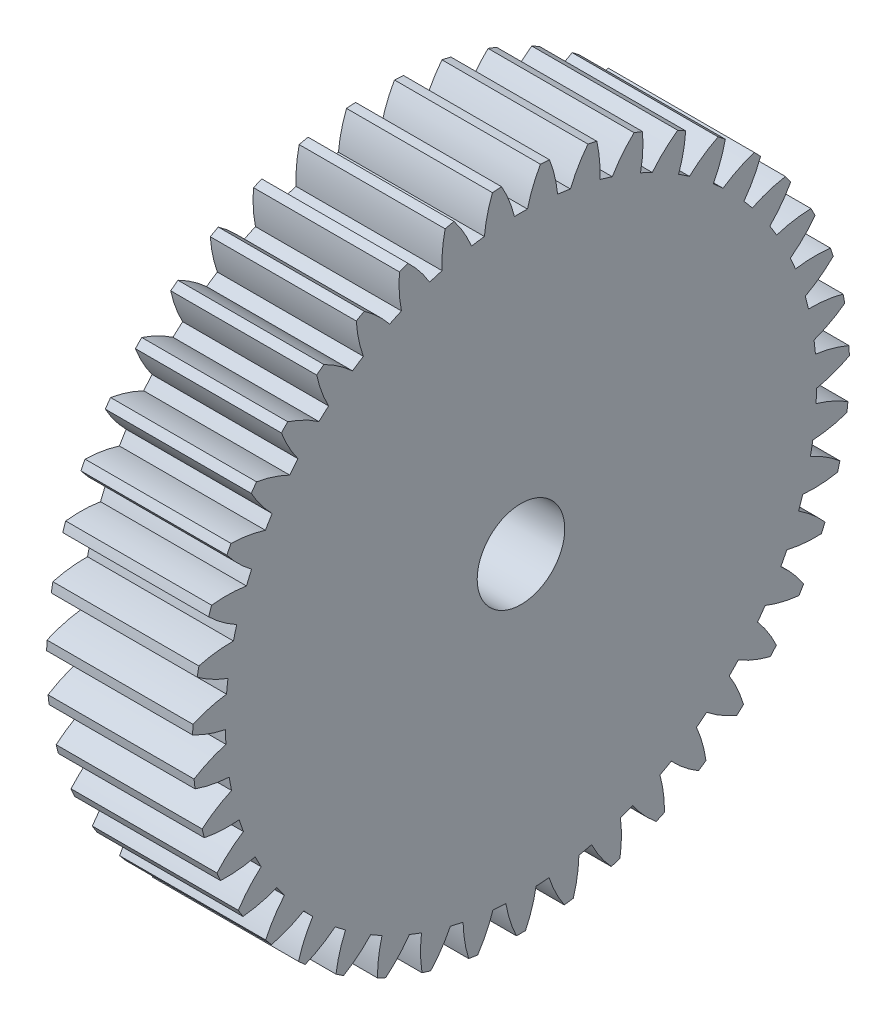
from build123d import *

# Parameters (mm, degrees)
BASPROSKE_W     = 10
BASPROSKE_H     = 22.5
TOOTHCUT_DEPTH  = 34.35416016
TEETHCUTS_COUNT = 43
TEETHCUTS_ANGLE = 351.627906977
BORSKE_R        = 3
BORE_DEPTH      = 50.0000508


with BuildPart() as part:
    # BasProSke → Base-Revolve (revolve)
    with BuildSketch(Plane(origin=(0, 0, 0), x_dir=(1, 0, 0), z_dir=(0, 1, 0)), mode=Mode.PRIVATE) as base_revolve_sk:
        with Locations((5, 11.25)):
            Rectangle(BASPROSKE_W, BASPROSKE_H)
    revolve(base_revolve_sk.sketch.rotate(Axis((-10, 0, 0), (1, 0, 0)), 180), axis=Axis((-10, 0, 0), (1, 0, 0)))

    # TooCutSke → ToothCut (cut, through all)
    with BuildSketch(Plane(origin=(0, 0, 0), x_dir=(0, 0, -1), z_dir=(1, 0, 0))):
        with BuildLine():
            ThreePointArc((0.444866364, 20.244112599), (0, 20.249), (-0.444866364, 20.244112599))
            ThreePointArc((-0.444866364, 20.244112599), (-0.81630868, 21.396424265), (-1.345889069, 22.48515572))
            ThreePointArc((-1.345889069, 22.48515572), (0, 22.5254), (1.345889069, 22.48515572))
            ThreePointArc((1.345889069, 22.48515572), (0.81630868, 21.396424265), (0.444866364, 20.244112599))
        make_face()
    toothcut = extrude(amount=TOOTHCUT_DEPTH, mode=Mode.SUBTRACT)

    # TeethCuts: ToothCut ×43 about axis
    teethcuts_axis = Axis((-10, 0, 0), (1, 0, 0))
    for i in range(1, TEETHCUTS_COUNT):
        add(toothcut.rotate(teethcuts_axis, i * TEETHCUTS_ANGLE / (TEETHCUTS_COUNT - 1)), mode=Mode.SUBTRACT)

    # BorSke → Bore (cut, symmetric)
    with BuildSketch(Plane(origin=(0, 0, 0), x_dir=(0, 0, -1), z_dir=(1, 0, 0))):
        with Locations(Location((0, 0, 0), (0, 0, 180))):
            Circle(BORSKE_R)
    extrude(amount=BORE_DEPTH, both=True, mode=Mode.SUBTRACT)


solid = part.part
